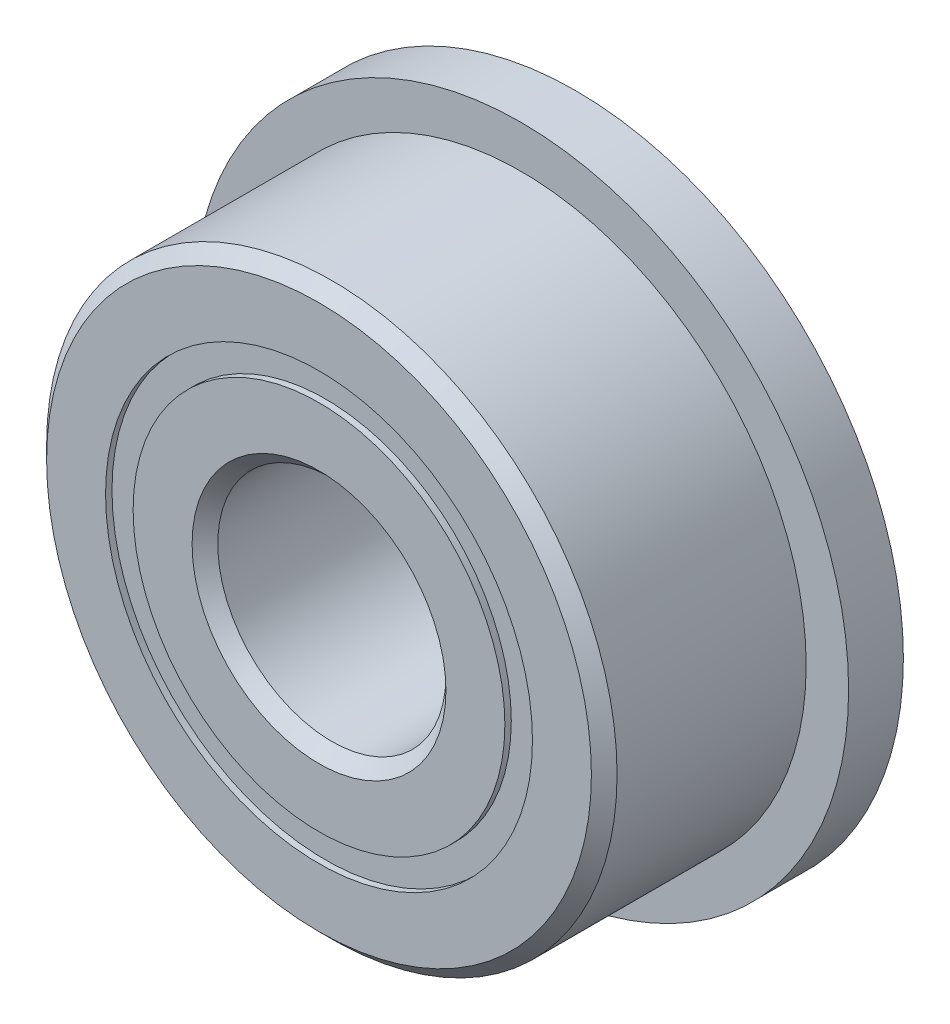
from build123d import *

# Parameters (mm, degrees)
CIRPATTERN1_COUNT = 12
SKETCH5_W         = 0.880023833
SKETCH5_H         = 0.383791208
SKETCH6_W         = 0.762
SKETCH6_H         = 1.589279396


with BuildPart() as part:
    # Sketch1 → Revolve1 (revolve)
    with BuildSketch(Plane(origin=(0, 0, 0), x_dir=(0, 0, -1), z_dir=(1, 0, 0))):
        with BuildLine():
            Line((1.60734375, 3.96875), (-1.60734375, 3.96875))
            Line((-1.60734375, 3.96875), (-1.7859375, 3.79015625))
            Line((-1.7859375, 3.79015625), (-1.7859375, 2.970020604))
            Line((-1.7859375, 2.970020604), (-0.79375, 2.970020604))
            ThreePointArc((-0.79375, 2.970020604), (0, 3.594741792), (0.79375, 2.970020604))
            Line((0.79375, 2.970020604), (1.7859375, 2.970020604))
            Line((1.7859375, 2.970020604), (1.7859375, 3.79015625))
            Line((1.7859375, 3.79015625), (1.60734375, 3.96875))
        make_face()
    revolve(axis=Axis((0, 0, 1.7859375), (0, 0, -1)))

    # Sketch6 → Revolve6 (revolve)
    with BuildSketch(Plane(origin=(0, 0, 0), x_dir=(0, 0, -1), z_dir=(1, 0, 0))):
        with Locations((1.4049375, 3.764660302)):
            Rectangle(SKETCH6_W, SKETCH6_H)
    revolve(axis=Axis((0, 0, -1.7859375), (0, 0, 1)))


with BuildPart() as body_2:
    # Sketch3 → Revolve3 (revolve)
    with BuildSketch(Plane(origin=(0, 0, 0), x_dir=(0, 0, -1), z_dir=(1, 0, 0))):
        with BuildLine():
            Line((-1.7859375, 2.586229396), (-0.79375, 2.586229396))
            ThreePointArc((-0.79375, 2.586229396), (0, 1.961508208), (0.79375, 2.586229396))
            Line((0.79375, 2.586229396), (1.7859375, 2.586229396))
            Line((1.7859375, 2.586229396), (1.7859375, 1.76609375))
            Line((1.7859375, 1.76609375), (1.60734375, 1.5875))
            Line((1.60734375, 1.5875), (-1.60734375, 1.5875))
            Line((-1.60734375, 1.5875), (-1.7859375, 1.76609375))
            Line((-1.7859375, 1.76609375), (-1.7859375, 2.586229396))
        make_face()
    revolve(axis=Axis((0, 0, 1.7859375), (0, 0, -1)))


with BuildPart() as body_3:
    # Sketch4 → Revolve4 (revolve)
    with BuildSketch(Plane(origin=(0, 0, 0), x_dir=(0, 0, -1), z_dir=(1, 0, 0))):
        with BuildLine():
            Line((-0.816616792, 2.778125), (0.816616792, 2.778125))
            ThreePointArc((0.816616792, 2.778125), (0, 3.594741792), (-0.816616792, 2.778125))
        make_face()
    revolve(axis=Axis((0, 2.778125, 0.816616792), (0, 0, -1)))


with BuildPart() as cirpattern1_1:
    # CirPattern1: pattern copy
    add(body_3.part.rotate(Axis((0, 0, -1.7859375), (0, 0, 1)), 1 * 360 / CIRPATTERN1_COUNT))


with BuildPart() as cirpattern1_2:
    # CirPattern1: pattern copy
    add(body_3.part.rotate(Axis((0, 0, -1.7859375), (0, 0, 1)), 2 * 360 / CIRPATTERN1_COUNT))


with BuildPart() as cirpattern1_3:
    # CirPattern1: pattern copy
    add(body_3.part.rotate(Axis((0, 0, -1.7859375), (0, 0, 1)), 3 * 360 / CIRPATTERN1_COUNT))


with BuildPart() as cirpattern1_4:
    # CirPattern1: pattern copy
    add(body_3.part.rotate(Axis((0, 0, -1.7859375), (0, 0, 1)), 4 * 360 / CIRPATTERN1_COUNT))


with BuildPart() as cirpattern1_5:
    # CirPattern1: pattern copy
    add(body_3.part.rotate(Axis((0, 0, -1.7859375), (0, 0, 1)), 5 * 360 / CIRPATTERN1_COUNT))


with BuildPart() as cirpattern1_6:
    # CirPattern1: pattern copy
    add(body_3.part.rotate(Axis((0, 0, -1.7859375), (0, 0, 1)), 6 * 360 / CIRPATTERN1_COUNT))


with BuildPart() as cirpattern1_7:
    # CirPattern1: pattern copy
    add(body_3.part.rotate(Axis((0, 0, -1.7859375), (0, 0, 1)), 7 * 360 / CIRPATTERN1_COUNT))


with BuildPart() as cirpattern1_8:
    # CirPattern1: pattern copy
    add(body_3.part.rotate(Axis((0, 0, -1.7859375), (0, 0, 1)), 8 * 360 / CIRPATTERN1_COUNT))


with BuildPart() as cirpattern1_9:
    # CirPattern1: pattern copy
    add(body_3.part.rotate(Axis((0, 0, -1.7859375), (0, 0, 1)), 9 * 360 / CIRPATTERN1_COUNT))


with BuildPart() as cirpattern1_10:
    # CirPattern1: pattern copy
    add(body_3.part.rotate(Axis((0, 0, -1.7859375), (0, 0, 1)), 10 * 360 / CIRPATTERN1_COUNT))


with BuildPart() as cirpattern1_11:
    # CirPattern1: pattern copy
    add(body_3.part.rotate(Axis((0, 0, -1.7859375), (0, 0, 1)), 11 * 360 / CIRPATTERN1_COUNT))


with BuildPart() as body_15:
    # Sketch5 → Revolve5 (revolve)
    with BuildSketch(Plane(origin=(0, 0, 0), x_dir=(0, 0, -1), z_dir=(1, 0, 0))):
        with Locations((-1.256628709, 2.778125)):
            Rectangle(SKETCH5_W, SKETCH5_H)
        with Locations((1.256628709, 2.778125)):
            Rectangle(SKETCH5_W, SKETCH5_H)
    revolve(axis=Axis((0, 0, 1.7859375), (0, 0, -1)))


solid = Compound([part.part, body_2.part, body_3.part, cirpattern1_1.part, cirpattern1_2.part, cirpattern1_3.part, cirpattern1_4.part, cirpattern1_5.part, cirpattern1_6.part, cirpattern1_7.part, cirpattern1_8.part, cirpattern1_9.part, cirpattern1_10.part, cirpattern1_11.part, body_15.part])
